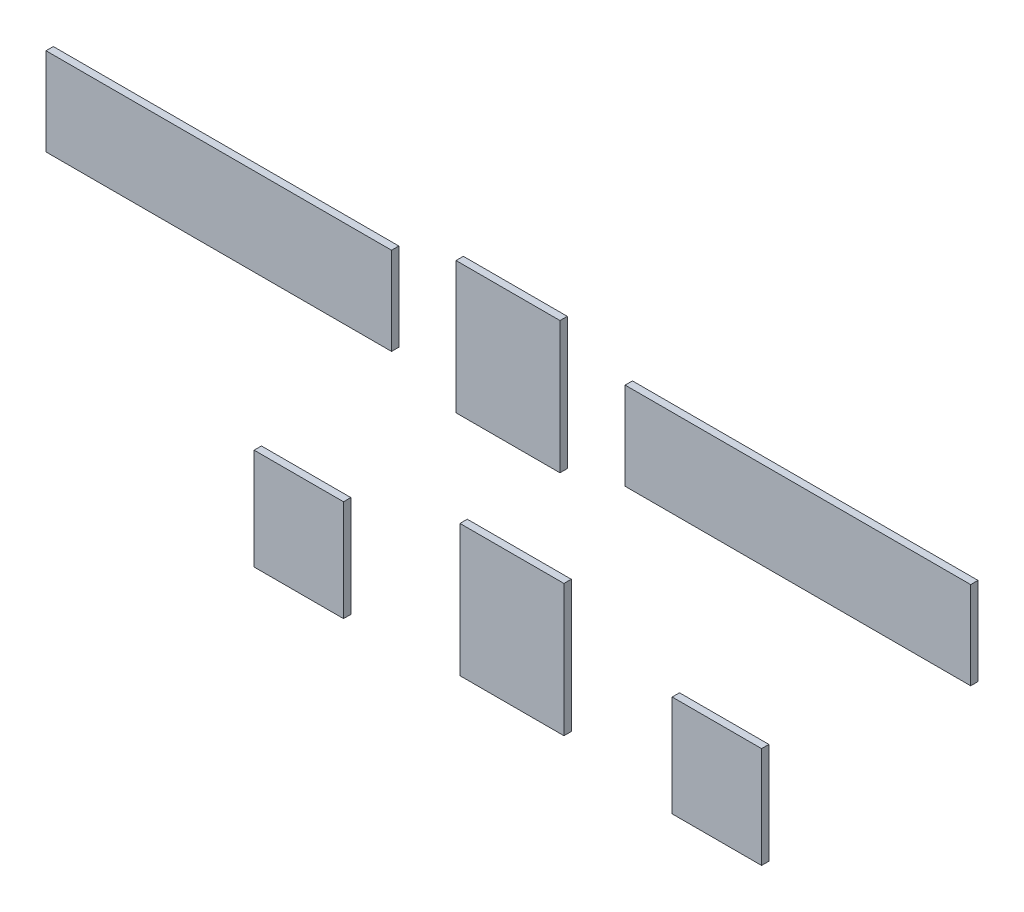
from build123d import *

# Parameters (mm, degrees)
SKETCH1_W             = 300
SKETCH1_H             = 76.108230447
BOSS_EXTRUDE1_DEPTH   = 6.35
BOSS_EXTRUDE1_2_DEPTH = 6.35
SKETCH1_W_2           = 90.255895431
SKETCH1_H_2           = 114.522810711
BOSS_EXTRUDE1_3_DEPTH = 6.35
BOSS_EXTRUDE1_4_DEPTH = 6.35
SKETCH1_W_3           = 77.598208687
SKETCH1_H_3           = 87.886173031
BOSS_EXTRUDE1_5_DEPTH = 6.35
BOSS_EXTRUDE1_6_DEPTH = 6.35


with BuildPart() as part:
    # Sketch1 → Boss-Extrude1 (new body)
    with BuildSketch(Plane.XY):
        with Locations((-245.443194985, 8.275954464)):
            Rectangle(SKETCH1_W, SKETCH1_H)
    extrude(amount=BOSS_EXTRUDE1_DEPTH)


with BuildPart() as body_2:
    # Sketch1 → Boss-Extrude1 2 (new body)
    with BuildSketch(Plane.XY):
        with Locations((257.356805015, 8.275954464)):
            Rectangle(SKETCH1_W, SKETCH1_H)
    extrude(amount=BOSS_EXTRUDE1_2_DEPTH)


with BuildPart() as body_3:
    # Sketch1 → Boss-Extrude1 3 (new body)
    with BuildSketch(Plane.XY):
        with Locations((9.100148196, -186.631990495)):
            Rectangle(SKETCH1_W_2, SKETCH1_H_2)
    extrude(amount=BOSS_EXTRUDE1_3_DEPTH)


with BuildPart() as body_4:
    # Sketch1 → Boss-Extrude1 4 (new body)
    with BuildSketch(Plane.XY):
        with Locations((5.648007274, 9.326418088)):
            Rectangle(SKETCH1_W_2, SKETCH1_H_2)
    extrude(amount=BOSS_EXTRUDE1_4_DEPTH)


with BuildPart() as body_5:
    # Sketch1 → Boss-Extrude1 5 (new body)
    with BuildSketch(Plane.XY):
        with Locations((-175.949133489, -207.588268368)):
            Rectangle(SKETCH1_W_3, SKETCH1_H_3)
    extrude(amount=BOSS_EXTRUDE1_5_DEPTH)


with BuildPart() as body_6:
    # Sketch1 → Boss-Extrude1 6 (new body)
    with BuildSketch(Plane.XY):
        with Locations((187.017124595, -211.701168091)):
            Rectangle(SKETCH1_W_3, SKETCH1_H_3)
    extrude(amount=BOSS_EXTRUDE1_6_DEPTH)


solid = Compound([part.part, body_2.part, body_3.part, body_4.part, body_5.part, body_6.part])
